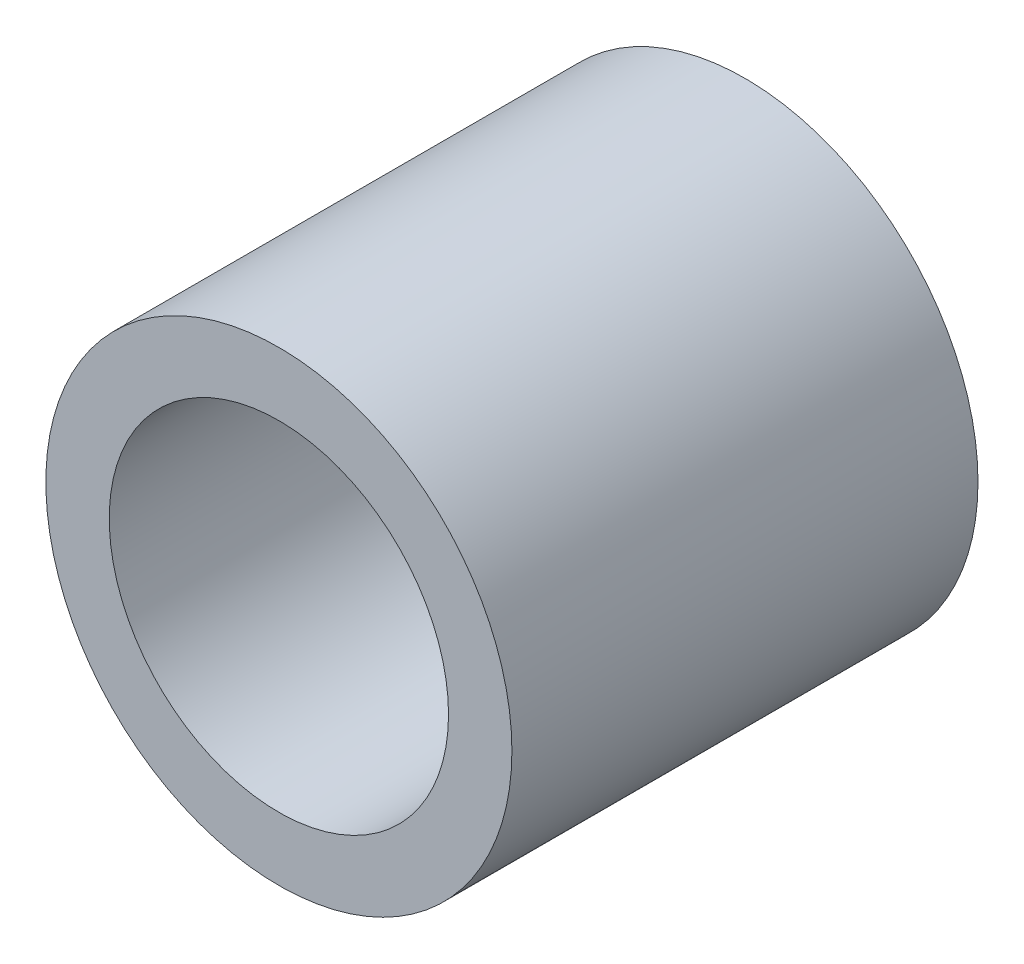
from build123d import *

# Parameters (mm, degrees)
SKETCH1_R           = 12.5
BOSS_EXTRUDE1_DEPTH = 40
SKETCH2_R           = 19
CUT_EXTRUDE1_DEPTH  = 15
SKETCH3_W           = 5.2
SKETCH3_H           = 3.2
CUT_EXTRUDE2_DEPTH  = 7
SKETCH4_R           = 9.1
CUT_EXTRUDE3_DEPTH  = 15


with BuildPart() as part:
    # Sketch1 → Boss-Extrude1 (new body)
    with BuildSketch(Plane.XY):
        Circle(SKETCH1_R)
    extrude(amount=BOSS_EXTRUDE1_DEPTH)

    # Sketch2 → Cut-Extrude1 (cut)
    with BuildSketch(Plane.XY.offset(40)):
        Circle(SKETCH2_R)
    extrude(amount=-CUT_EXTRUDE1_DEPTH, mode=Mode.SUBTRACT)

    # Sketch3 → Cut-Extrude2 (cut)
    with BuildSketch(Plane(origin=(0, 0, 0), x_dir=(-1, 0, 0), z_dir=(0, 0, -1))):
        Rectangle(SKETCH3_W, SKETCH3_H)
    extrude(amount=-CUT_EXTRUDE2_DEPTH, mode=Mode.SUBTRACT)

    # Sketch4 → Cut-Extrude3 (cut)
    with BuildSketch(Plane.XY.offset(25)):
        Circle(SKETCH4_R)
    extrude(amount=-CUT_EXTRUDE3_DEPTH, mode=Mode.SUBTRACT)


solid = part.part
